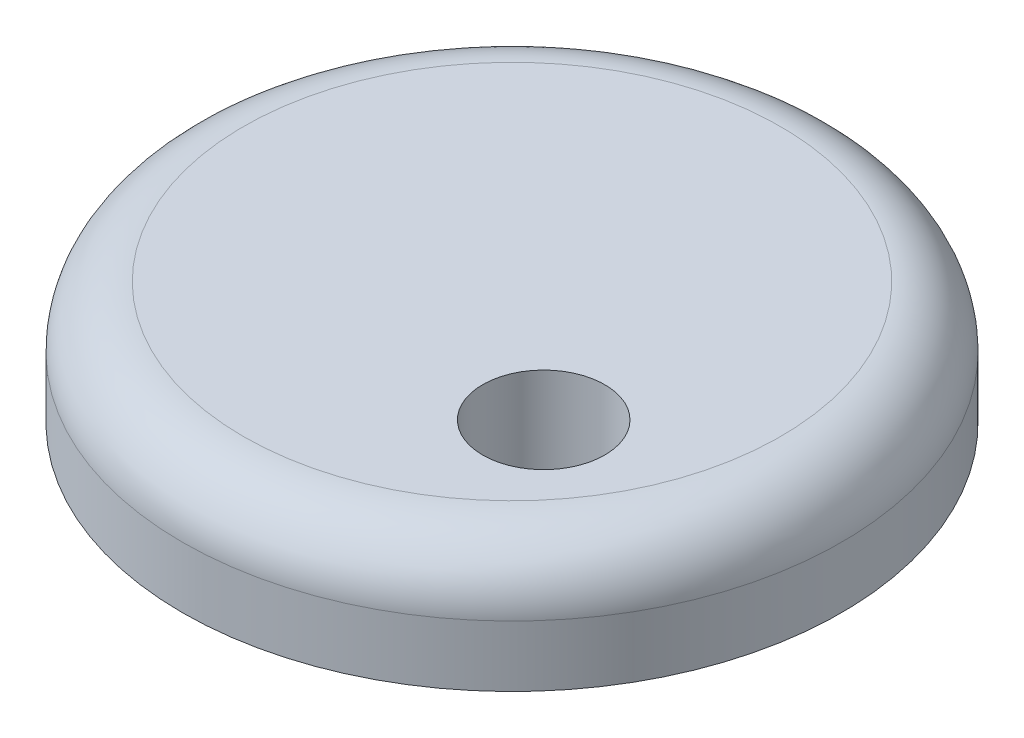
from build123d import *

# Parameters (mm, degrees)
SKETCH1_R           = 27
BOSS_EXTRUDE1_DEPTH = 10
FILLET1_R           = 5
SKETCH2_R           = 5
CUT_EXTRUDE1_DEPTH  = 10


with BuildPart() as part:
    # Sketch1 → Boss-Extrude1 (new body)
    with BuildSketch(Plane(origin=(0, 0, 0), x_dir=(1, 0, 0), z_dir=(0, 1, 0))):
        Circle(SKETCH1_R)
    extrude(amount=BOSS_EXTRUDE1_DEPTH)

    # Fillet1
    fillet1_edges = [part.edges().sort_by_distance(p)[0] for p in [
        (-27, 10, 0),
    ]]
    fillet(fillet1_edges, radius=FILLET1_R)

    # Sketch2 → Cut-Extrude1 (cut)
    with BuildSketch(Plane(origin=(0, 10, 0), x_dir=(1, 0, 0), z_dir=(0, 1, 0))):
        with Locations((11.112679592, -8.515183631)):
            Circle(SKETCH2_R)
    extrude(amount=-CUT_EXTRUDE1_DEPTH, mode=Mode.SUBTRACT)


solid = part.part
